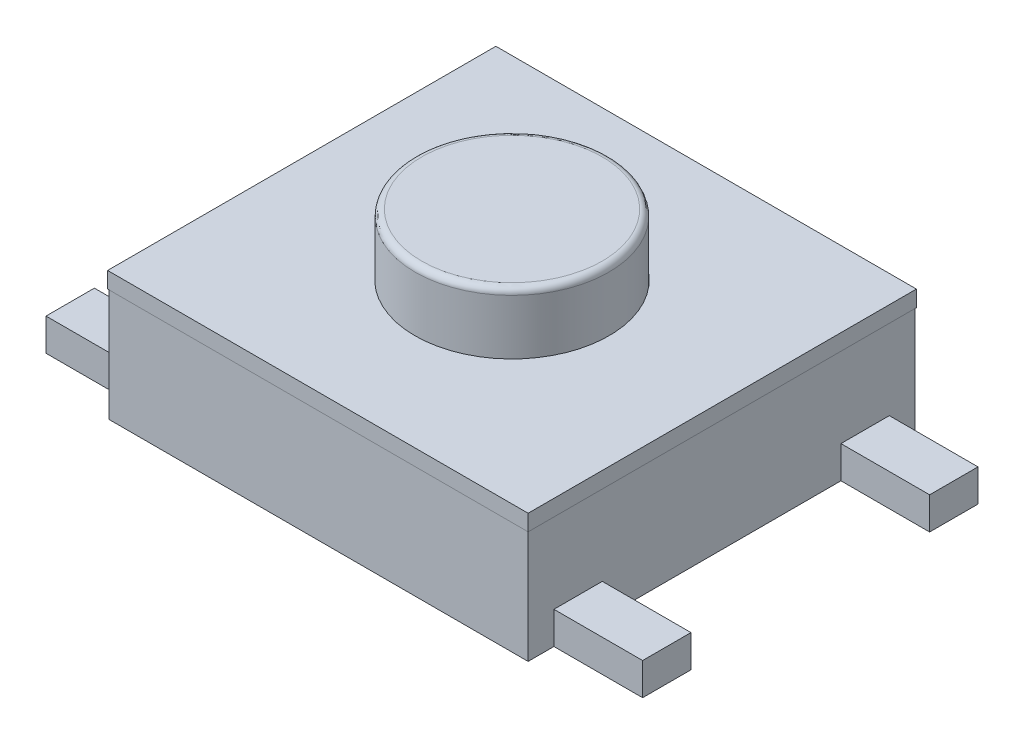
from build123d import *

# Parameters (mm, degrees)
SKETCH1_W           = 6.5
SKETCH1_H           = 6
BOSS_EXTRUDE1_DEPTH = 1.75
SKETCH2_W           = 6.52
SKETCH2_H           = 6.02
SKETCH2_R           = 1.505
BOSS_EXTRUDE2_DEPTH = 0.25
SKETCH3_R           = 1.5
BOSS_EXTRUDE3_DEPTH = 1.2
FILLET1_R           = 0.1
SKETCH4_W           = 1.375
SKETCH4_H           = 0.75
BOSS_EXTRUDE4_DEPTH = 0.5


with BuildPart() as part:
    # Sketch1 → Boss-Extrude1 (new body)
    with BuildSketch(Plane(origin=(0, 0, 0), x_dir=(1, 0, 0), z_dir=(0, 1, 0))):
        Rectangle(SKETCH1_W, SKETCH1_H)
    extrude(amount=BOSS_EXTRUDE1_DEPTH)

    # Sketch2 → Boss-Extrude2 (add)
    with BuildSketch(Plane(origin=(0, 1.75, 0), x_dir=(1, 0, 0), z_dir=(0, 1, 0))):
        Rectangle(SKETCH2_W, SKETCH2_H)
        Circle(SKETCH2_R, mode=Mode.SUBTRACT)
    extrude(amount=BOSS_EXTRUDE2_DEPTH)

    # Sketch3 → Boss-Extrude3 (add)
    with BuildSketch(Plane(origin=(0, 1.75, 0), x_dir=(1, 0, 0), z_dir=(0, 1, 0))):
        Circle(SKETCH3_R)
    extrude(amount=BOSS_EXTRUDE3_DEPTH)

    # Fillet1
    fillet1_edges = [part.edges().sort_by_distance(p)[0] for p in [
        (-1.5, 2.95, 0),
    ]]
    fillet(fillet1_edges, radius=FILLET1_R)

    # Sketch4 → Boss-Extrude4 (add)
    with BuildSketch(Plane.XZ):
        with Locations((3.9375, 2.225)):
            Rectangle(SKETCH4_W, SKETCH4_H)
        with Locations((3.9375, -2.225)):
            Rectangle(SKETCH4_W, SKETCH4_H)
        with Locations((-3.9375, -2.225)):
            Rectangle(SKETCH4_W, SKETCH4_H)
        with Locations((-3.9375, 2.225)):
            Rectangle(SKETCH4_W, SKETCH4_H)
        with Locations((-3.9375, 0)):
            Rectangle(SKETCH4_W, SKETCH4_H)
    extrude(amount=-BOSS_EXTRUDE4_DEPTH)


solid = part.part
